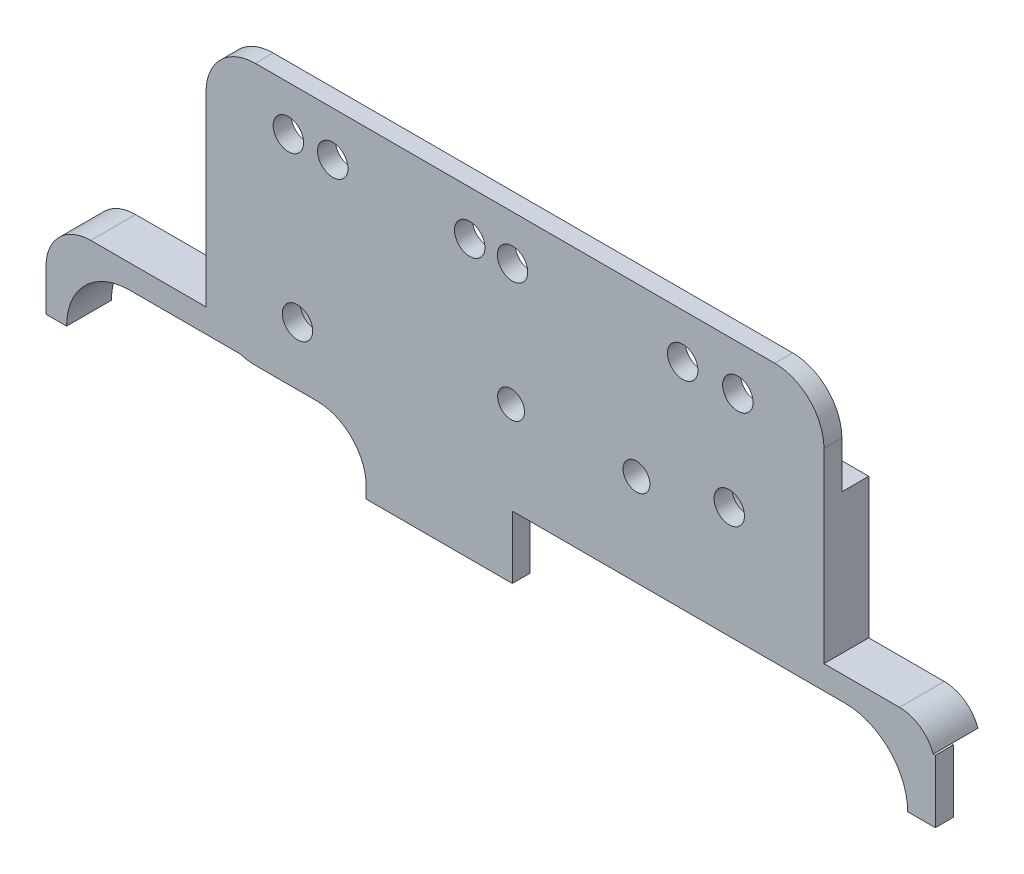
from build123d import *

# Parameters (mm, degrees)
ESQUISSE1_R             = 1.7
BOSS_EXTRU_1_DEPTH      = 3
BOSS_EXTRU_2_DEPTH      = 3
BOSS_EXTRU_2_DEPTH_BACK = 3
ESQUISSE2_R             = 5.2
ESQUISSE5_W             = 129.390100882
ESQUISSE5_H             = 120.053414285
ENL_V_MAT_EXTRU_2_DEPTH = 1
ESQUISSE6_R             = 1.5
ENL_V_MAT_EXTRU_3_DEPTH = 8
ESQUISSE7_W             = 14.610679854
ESQUISSE7_H             = 62.75
ENL_V_MAT_EXTRU_4_DEPTH = 8
BOSS_EXTRU_3_DEPTH      = 7
BOSS_EXTRU_4_DEPTH      = 7
ESQUISSE11_W            = 149.051338644
ESQUISSE11_H            = 13.366564364
ENL_V_MAT_EXTRU_5_DEPTH = 80
ESQUISSE13_R            = 1.7
ENL_V_MAT_EXTRU_6_DEPTH = 15


with BuildPart() as part:
    # Esquisse1 → Boss.-Extru.1 (new body)
    with BuildSketch(Plane.XY):
        with BuildLine():
            Line((-117.680084405, 66.939310237), (-117.680084405, 59.695120061))
            ThreePointArc((-117.680084405, 59.695120061), (-116.069171702, 55.806032765), (-112.180084405, 54.195120061))
            Line((-112.180084405, 54.195120061), (-105.294175096, 54.195120061))
            ThreePointArc((-105.294175096, 54.195120061), (-101.4050878, 52.584207358), (-99.794175096, 48.695120061))
            Line((-99.794175096, 48.695120061), (-99.794175096, 35.930823665))
            ThreePointArc((-99.794175096, 35.930823665), (-101.4050878, 32.041736368), (-105.294175096, 30.430823665))
            Line((-105.294175096, 30.430823665), (-112.180084405, 30.430823665))
            ThreePointArc((-112.180084405, 30.430823665), (-116.069171702, 28.819910961), (-117.680084405, 24.930823665))
            Line((-117.680084405, 24.930823665), (-117.680084405, 23.910007682))
            ThreePointArc((-117.680084405, 23.910007682), (-116.069171702, 20.020920385), (-112.180084405, 18.410007682))
            Line((-112.180084405, 18.410007682), (-105.294175096, 18.410007682))
            ThreePointArc((-105.294175096, 18.410007682), (-101.4050878, 16.799094979), (-99.794175096, 12.910007682))
            Line((-99.794175096, 12.910007682), (-99.794175096, 1.692208933))
            ThreePointArc((-99.794175096, 1.692208933), (-101.4050878, -2.196878364), (-105.294175096, -3.807791067))
            Line((-105.294175096, -3.807791067), (-113.390601299, -3.807791067))
            ThreePointArc((-113.390601299, -3.807791067), (-117.279688595, -5.418703771), (-118.890601299, -9.307791067))
            Line((-118.890601299, -9.307791067), (-118.890601299, -18.42196685))
            ThreePointArc((-118.890601299, -18.42196685), (-117.279688595, -22.311054147), (-113.390601299, -23.92196685))
            Line((-113.390601299, -23.92196685), (-52.866544484, -23.92196685))
            ThreePointArc((-52.866544484, -23.92196685), (-48.977457187, -22.311054147), (-47.366544484, -18.42196685))
            Line((-47.366544484, -18.42196685), (-47.366544484, -9.307791067))
            ThreePointArc((-47.366544484, -9.307791067), (-48.977457187, -5.418703771), (-52.866544484, -3.807791067))
            Line((-52.866544484, -3.807791067), (-77.986378892, -3.807791067))
            ThreePointArc((-77.986378892, -3.807791067), (-81.875466189, -2.196878364), (-83.486378892, 1.692208933))
            Line((-83.486378892, 1.692208933), (-83.486378892, 12.910007682))
            ThreePointArc((-83.486378892, 12.910007682), (-81.875466189, 16.799094979), (-77.986378892, 18.410007682))
            Line((-77.986378892, 18.410007682), (-69.856378892, 18.410007682))
            ThreePointArc((-69.856378892, 18.410007682), (-65.967291596, 20.020920385), (-64.356378892, 23.910007682))
            Line((-64.356378892, 23.910007682), (-64.356378892, 24.930823665))
            ThreePointArc((-64.356378892, 24.930823665), (-65.967291596, 28.819910961), (-69.856378892, 30.430823665))
            Line((-69.856378892, 30.430823665), (-77.986378892, 30.430823665))
            ThreePointArc((-77.986378892, 30.430823665), (-81.875466189, 32.041736368), (-83.486378892, 35.930823665))
            Line((-83.486378892, 35.930823665), (-83.486378892, 55.219310237))
            ThreePointArc((-83.486378892, 55.219310237), (-81.875466189, 59.108397534), (-77.986378892, 60.719310237))
            Line((-77.986378892, 60.719310237), (-54.190366806, 60.719310237))
            ThreePointArc((-54.190366806, 60.719310237), (-50.30127951, 62.330222941), (-48.690366806, 66.219310237))
            Line((-48.690366806, 66.219310237), (-48.690366806, 67.219310237))
            Line((-48.690366806, 67.219310237), (-48.690366806, 77.901748252))
            ThreePointArc((-48.690366806, 77.901748252), (-50.30127951, 81.790835548), (-54.190366806, 83.401748252))
            Line((-54.190366806, 83.401748252), (-112.180084405, 83.401748252))
            ThreePointArc((-112.180084405, 83.401748252), (-116.069171702, 81.790835548), (-117.680084405, 77.901748252))
            Line((-117.680084405, 77.901748252), (-117.680084405, 67.219310237))
            Line((-117.680084405, 67.219310237), (-117.680084405, 66.939310237))
        make_face()
        with Locations((-59.266378892, -15.663707737)):
            Circle(ESQUISSE1_R, mode=Mode.SUBTRACT)
        with Locations((-59.266378892, 66.939310237)):
            Circle(ESQUISSE1_R, mode=Mode.SUBTRACT)
        with Locations((-91.856378892, 36.719310237)):
            Circle(ESQUISSE1_R, mode=Mode.SUBTRACT)
        with Locations((-107.466378892, -14.520689763)):
            Circle(ESQUISSE1_R, mode=Mode.SUBTRACT)
        with Locations((-107.466378892, 60.719310237)):
            Circle(ESQUISSE1_R, mode=Mode.SUBTRACT)
        with Locations((-58.306378892, 78.399310237)):
            Circle(ESQUISSE1_R, mode=Mode.SUBTRACT)
        with Locations((-108.486378892, 78.399310237)):
            Circle(ESQUISSE1_R, mode=Mode.SUBTRACT)
        with BuildLine():
            Line((-111.390601299, 21.460065469), (-70.086378892, 21.460065469))
            ThreePointArc((-70.086378892, 21.460065469), (-68.67216533, 22.045851906), (-68.086378892, 23.460065469))
            Line((-68.086378892, 23.460065469), (-68.086378892, 24.842520386))
            ThreePointArc((-68.086378892, 24.842520386), (-68.67216533, 26.256733949), (-70.086378892, 26.842520386))
            Line((-70.086378892, 26.842520386), (-111.390601299, 26.842520386))
            ThreePointArc((-111.390601299, 26.842520386), (-112.804814861, 26.256733949), (-113.390601299, 24.842520386))
            Line((-113.390601299, 24.842520386), (-113.390601299, 23.460065469))
            ThreePointArc((-113.390601299, 23.460065469), (-112.804814861, 22.045851906), (-111.390601299, 21.460065469))
        make_face(mode=Mode.SUBTRACT)
    extrude(amount=BOSS_EXTRU_1_DEPTH)

    # Esquisse2 → Boss.-Extru.2 (add, two sides: drawn at the far end of the back side and taken through both)
    with BuildSketch(Plane(origin=(0, 0, 0), x_dir=(-1, 0, 0), z_dir=(0, 0, -1)).offset(-BOSS_EXTRU_2_DEPTH_BACK)):
        with BuildLine():
            Line((118.890601299, -9.969506719), (130.584615963, -9.880075131))
            ThreePointArc((130.584615963, -9.880075131), (134.095405897, -8.402210456), (135.546378892, -4.880221341))
            Line((135.546378892, -4.880221341), (135.546378892, 5.415623015))
            ThreePointArc((135.546378892, 5.415623015), (136.425058549, 7.536943358), (138.546378892, 8.415623015))
            Line((138.546378892, 8.415623015), (145.752654566, 8.415623015))
            ThreePointArc((145.752654566, 8.415623015), (147.87397491, 9.294302671), (148.752654566, 11.415623015))
            Line((148.752654566, 11.415623015), (148.752654566, 38.179170847))
            ThreePointArc((148.752654566, 38.179170847), (147.87397491, 40.300491191), (145.752654566, 41.179170847))
            Line((145.752654566, 41.179170847), (138.546378892, 41.179170847))
            ThreePointArc((138.546378892, 41.179170847), (136.425058549, 42.057850504), (135.546378892, 44.179170847))
            Line((135.546378892, 44.179170847), (135.546378892, 52.099902349))
            ThreePointArc((135.546378892, 52.099902349), (134.081912798, 55.635436255), (130.546378892, 57.099902349))
            Line((130.546378892, 57.099902349), (117.680084405, 57.099902349))
            Line((117.680084405, 57.099902349), (117.680084405, 72.719310237))
            Line((117.680084405, 72.719310237), (48.690366806, 72.719310237))
            Line((48.690366806, 72.719310237), (48.690366806, 60.719310237))
            Line((48.690366806, 60.719310237), (48.690366806, 57.099902349))
            Line((48.690366806, 57.099902349), (40.256901013, 57.099902349))
            ThreePointArc((40.256901013, 57.099902349), (37.428473888, 55.928329474), (36.256901013, 53.099902349))
            Line((36.256901013, 53.099902349), (36.256901013, 47.456292263))
            Line((36.256901013, 47.456292263), (39.346378892, 47.456292263))
            ThreePointArc((39.346378892, 47.456292263), (41.396631424, 52.406039732), (46.346378892, 54.456292263))
            Line((46.346378892, 54.456292263), (126.246378892, 54.456292263))
            ThreePointArc((126.246378892, 54.456292263), (131.196126361, 52.406039732), (133.246378892, 47.456292263))
            Line((133.246378892, 47.456292263), (133.246378892, 40.977229779))
            ThreePointArc((133.246378892, 40.977229779), (134.125058549, 38.855909436), (136.246378892, 37.977229779))
            Line((136.246378892, 37.977229779), (142.162261637, 37.977229779))
            ThreePointArc((142.162261637, 37.977229779), (144.28358198, 37.098550123), (145.162261637, 34.977229779))
            Line((145.162261637, 34.977229779), (145.162261637, 14.363062522))
            ThreePointArc((145.162261637, 14.363062522), (144.28358198, 12.241742179), (142.162261637, 11.363062522))
            Line((142.162261637, 11.363062522), (136.246378892, 11.363062522))
            ThreePointArc((136.246378892, 11.363062522), (134.125058549, 10.484382866), (133.246378892, 8.363062522))
            Line((133.246378892, 8.363062522), (133.246378892, -1.293707737))
            ThreePointArc((133.246378892, -1.293707737), (131.196126361, -6.243455205), (126.246378892, -8.293707737))
            Line((126.246378892, -8.293707737), (46.346378892, -8.293707737))
            ThreePointArc((46.346378892, -8.293707737), (41.396631424, -6.243455205), (39.346378892, -1.293707737))
            Line((39.346378892, -1.293707737), (36.248203357, -1.293707737))
            Line((36.248203357, -1.293707737), (36.248203357, -6.64542392))
            ThreePointArc((36.248203357, -6.64542392), (37.432020164, -9.486042202), (40.282759469, -10.645274652))
            Line((40.282759469, -10.645274652), (47.366544484, -10.58407535))
            Line((47.366544484, -10.58407535), (47.366544484, -23.92196685))
            Line((47.366544484, -23.92196685), (118.890601299, -23.92196685))
            Line((118.890601299, -23.92196685), (118.890601299, -9.969506719))
        make_face()
        with Locations((59.266378892, -15.663707737)):
            Circle(ESQUISSE2_R, mode=Mode.SUBTRACT)
        with Locations((107.466378892, -14.520689763)):
            Circle(ESQUISSE2_R, mode=Mode.SUBTRACT)
        with Locations((107.466378892, 60.719310237)):
            Circle(ESQUISSE2_R, mode=Mode.SUBTRACT)
        with Locations((59.266378892, 66.939310237)):
            Circle(ESQUISSE2_R, mode=Mode.SUBTRACT)
    extrude(amount=BOSS_EXTRU_2_DEPTH + BOSS_EXTRU_2_DEPTH_BACK)

    # Esquisse5 → Enlèv. mat.-Extru.2 (cut)
    with BuildSketch(Plane.XY.offset(3)):
        with Locations((-91.695706627, 29.828971757)):
            Rectangle(ESQUISSE5_W, ESQUISSE5_H)
    extrude(amount=-ENL_V_MAT_EXTRU_2_DEPTH, mode=Mode.SUBTRACT)

    # Esquisse6 → Enlèv. mat.-Extru.3 (cut)
    with BuildSketch(Plane.XY.offset(2)):
        with Locations((-69.623492164, 64.727424081)):
            Circle(ESQUISSE6_R)
        with Locations((-83.623492164, 64.727424081)):
            Circle(ESQUISSE6_R)
    extrude(amount=-ENL_V_MAT_EXTRU_3_DEPTH, mode=Mode.SUBTRACT)

    # Esquisse7 → Enlèv. mat.-Extru.4 (cut)
    with BuildSketch(Plane(origin=(0, 0, 0), x_dir=(-1, 0, 0), z_dir=(0, 0, -1))):
        with Locations((42.567758063, 23.081292263)):
            Rectangle(ESQUISSE7_W, ESQUISSE7_H)
    extrude(amount=ENL_V_MAT_EXTRU_4_DEPTH, mode=Mode.SUBTRACT)

    # Esquisse9 → Boss.-Extru.3 (add)
    with BuildSketch(Plane(origin=(0, -1.293707737, 0), x_dir=(1, 0, 0), z_dir=(0, 1, 0))):
        Polygon((-39.346378892, -2), (-39.346378892, 0.886005049), (-36.248203357, 0), (-36.248203357, -2), align=None)
    extrude(amount=-BOSS_EXTRU_3_DEPTH)

    # Esquisse10 → Boss.-Extru.4 (add)
    with BuildSketch(Plane.XZ.offset(-47.456292263)):
        Polygon((-39.346378892, 2), (-39.346378892, -0.873043126), (-36.256901013, 0), (-36.256901013, 2), align=None)
    extrude(amount=-BOSS_EXTRU_4_DEPTH)

    # Esquisse11 → Enlèv. mat.-Extru.5 (cut)
    with BuildSketch(Plane.XZ.offset(-47.456292263)):
        with Locations((-92.889015797, -0.494206667)):
            Rectangle(ESQUISSE11_W, ESQUISSE11_H)
    extrude(amount=ENL_V_MAT_EXTRU_5_DEPTH, mode=Mode.SUBTRACT)

    # Esquisse13 → Enlèv. mat.-Extru.6 (cut)
    with BuildSketch(Plane.XY.offset(2)):
        with Locations((-103.52911982, 78.399310237)):
            Circle(ESQUISSE13_R)
        with Locations((-88.23911982, 78.399310237)):
            Circle(ESQUISSE13_R)
        with Locations((-83.462080633, 78.399310237)):
            Circle(ESQUISSE13_R)
        with Locations((-64.462080633, 78.399310237)):
            Circle(ESQUISSE13_R)
    extrude(amount=-ENL_V_MAT_EXTRU_6_DEPTH, mode=Mode.SUBTRACT)


solid = part.part
